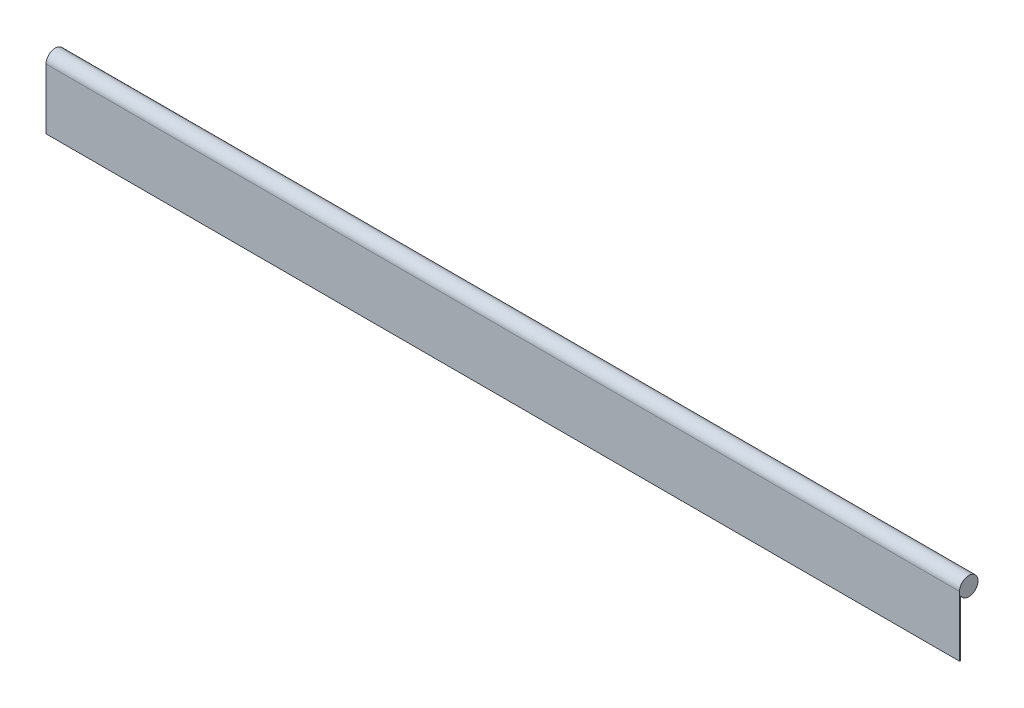
from build123d import *

# Parameters (mm, degrees)
BOSS_EXTRUDE1_DEPTH = 1727.2


with BuildPart() as part:
    # Sketch1 → Boss-Extrude1 (new body)
    with BuildSketch(Plane(origin=(0, 0, 0), x_dir=(0, 0, -1), z_dir=(1, 0, 0))):
        with BuildLine():
            Line((-17.4625, 0), (-17.4625, -114.3))
            Line((-17.4625, -114.3), (-15.875, -114.3))
            Line((-15.875, -114.3), (-15.875, -7.274838916))
            ThreePointArc((-15.875, -7.274838916), (17.06100955, 3.723017509), (-17.4625, 0))
        make_face()
    extrude(amount=BOSS_EXTRUDE1_DEPTH)


solid = part.part
